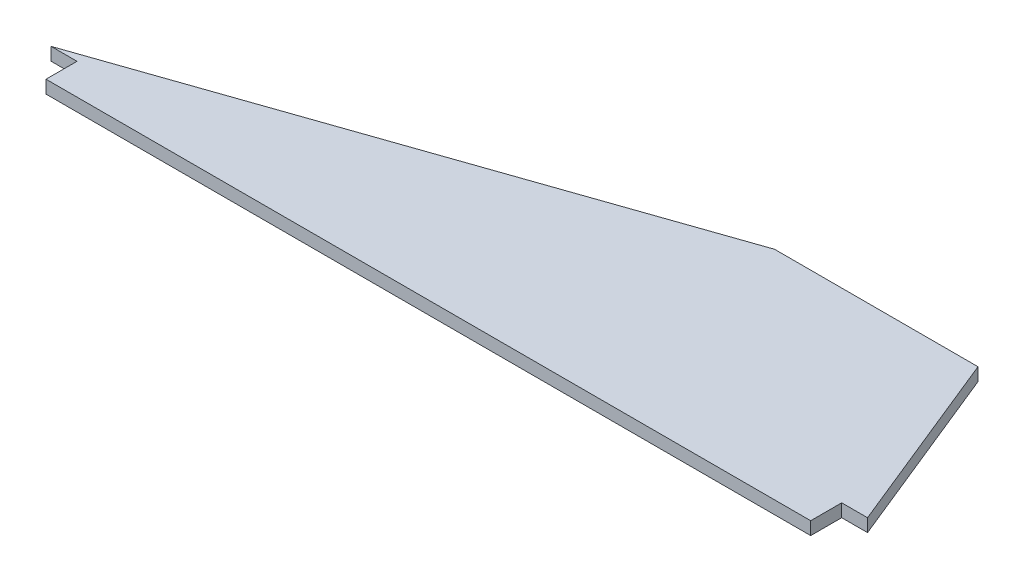
from build123d import *

# Parameters (mm, degrees)
BOSS_EXTRUDE1_DEPTH = 3.175


with BuildPart() as part:
    # Sketch1 → Boss-Extrude1 (new body)
    with BuildSketch(Plane(origin=(0, 0, 0), x_dir=(1, 0, 0), z_dir=(0, 1, 0))):
        Polygon((0, 0), (132.08, 45.72), (182.0926, 45.72), (200.66, 0), (194.31, 0), (194.31, -7.62), (6.35, -7.62), (6.35, 0), align=None)
    extrude(amount=BOSS_EXTRUDE1_DEPTH)


solid = part.part
